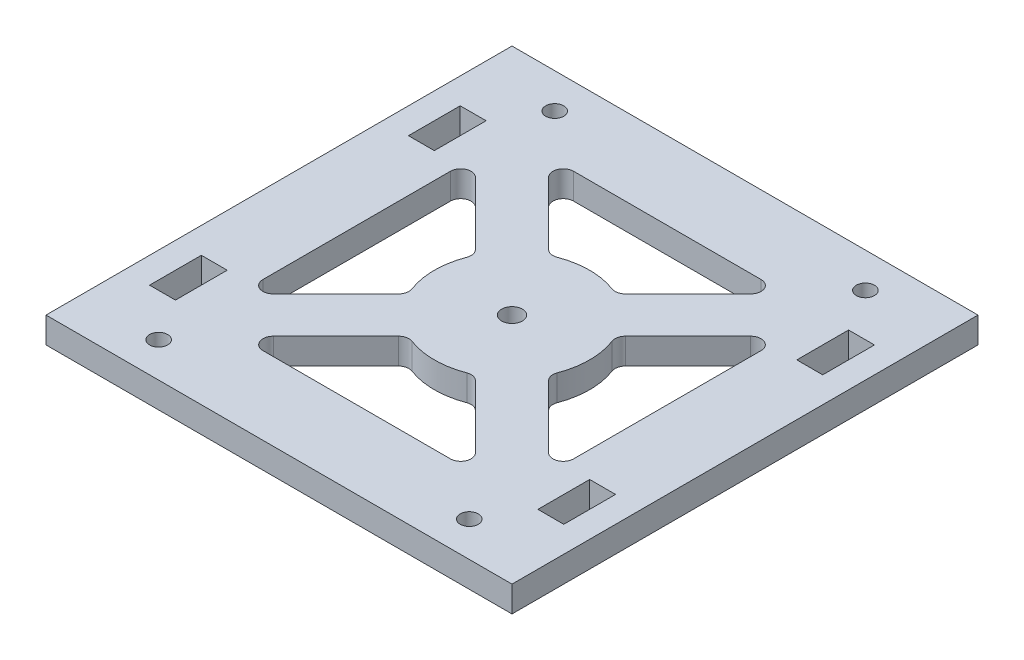
from build123d import *

# Parameters (mm, degrees)
SKETCH1_W               = 90
SKETCH1_H               = 90
SKETCH1_R               = 2
BOSS_EXTRUDE1_DEPTH     = 5
SKETCH2_R               = 1.75
SKETCH2_W               = 5
SKETCH2_H               = 10
CUT_EXTRUDE1_DEPTH      = 1
CUT_EXTRUDE1_DEPTH_BACK = 6


with BuildPart() as part:
    # Sketch1 → Boss-Extrude1 (new body)
    with BuildSketch(Plane(origin=(0, 0, 0), x_dir=(1, 0, 0), z_dir=(0, 1, 0))):
        Rectangle(SKETCH1_W, SKETCH1_H)
        Circle(SKETCH1_R, mode=Mode.SUBTRACT)
        with BuildLine():
            Line((-26.585786438, 19.514718626), (-14.489985056, 7.418917244))
            ThreePointArc((-14.489985056, 7.418917244), (-13.949056578, 6.425915745), (-14.033116428, 5.298267955))
            ThreePointArc((-14.033116428, 5.298267955), (-15, 0), (-14.033116428, -5.298267955))
            ThreePointArc((-14.033116428, -5.298267955), (-13.949056578, -6.425915745), (-14.489985056, -7.418917244))
            Line((-14.489985056, -7.418917244), (-26.585786438, -19.514718626))
            ThreePointArc((-26.585786438, -19.514718626), (-28.765366865, -19.948264128), (-30, -18.100505063))
            Line((-30, -18.100505063), (-30, 18.100505063))
            ThreePointArc((-30, 18.100505063), (-28.765366865, 19.948264128), (-26.585786438, 19.514718626))
        make_face(mode=Mode.SUBTRACT)
        with BuildLine():
            Line((-18.100505063, 30), (18.100505063, 30))
            ThreePointArc((18.100505063, 30), (19.948264128, 28.765366865), (19.514718626, 26.585786438))
            Line((19.514718626, 26.585786438), (7.418917244, 14.489985056))
            ThreePointArc((7.418917244, 14.489985056), (6.425915745, 13.949056578), (5.298267955, 14.033116428))
            ThreePointArc((5.298267955, 14.033116428), (0, 15), (-5.298267955, 14.033116428))
            ThreePointArc((-5.298267955, 14.033116428), (-6.425915745, 13.949056578), (-7.418917244, 14.489985056))
            Line((-7.418917244, 14.489985056), (-19.514718626, 26.585786438))
            ThreePointArc((-19.514718626, 26.585786438), (-19.948264128, 28.765366865), (-18.100505063, 30))
        make_face(mode=Mode.SUBTRACT)
        with BuildLine():
            Line((30, 18.100505063), (30, -18.100505063))
            ThreePointArc((30, -18.100505063), (28.765366865, -19.948264128), (26.585786438, -19.514718626))
            Line((26.585786438, -19.514718626), (14.489985056, -7.418917244))
            ThreePointArc((14.489985056, -7.418917244), (13.949056578, -6.425915745), (14.033116428, -5.298267955))
            ThreePointArc((14.033116428, -5.298267955), (15, 0), (14.033116428, 5.298267955))
            ThreePointArc((14.033116428, 5.298267955), (13.949056578, 6.425915745), (14.489985056, 7.418917244))
            Line((14.489985056, 7.418917244), (26.585786438, 19.514718626))
            ThreePointArc((26.585786438, 19.514718626), (28.765366865, 19.948264128), (30, 18.100505063))
        make_face(mode=Mode.SUBTRACT)
        with BuildLine():
            Line((19.514718626, -26.585786438), (7.418917244, -14.489985056))
            ThreePointArc((7.418917244, -14.489985056), (6.425915745, -13.949056578), (5.298267955, -14.033116428))
            ThreePointArc((5.298267955, -14.033116428), (0, -15), (-5.298267955, -14.033116428))
            ThreePointArc((-5.298267955, -14.033116428), (-6.425915745, -13.949056578), (-7.418917244, -14.489985056))
            Line((-7.418917244, -14.489985056), (-19.514718626, -26.585786438))
            ThreePointArc((-19.514718626, -26.585786438), (-19.948264128, -28.765366865), (-18.100505063, -30))
            Line((-18.100505063, -30), (18.100505063, -30))
            ThreePointArc((18.100505063, -30), (19.948264128, -28.765366865), (19.514718626, -26.585786438))
        make_face(mode=Mode.SUBTRACT)
    extrude(amount=BOSS_EXTRUDE1_DEPTH)

    # Sketch2 → Cut-Extrude1 (cut, two sides)
    with BuildSketch(Plane(origin=(0, 5, 0), x_dir=(1, 0, 0), z_dir=(0, 1, 0))) as cut_extrude1_sk:
        with Locations((-30, -38.25)):
            Circle(SKETCH2_R)
        with Locations((30, -38.25)):
            Circle(SKETCH2_R)
        with Locations((30, 38.25)):
            Circle(SKETCH2_R)
        with Locations((-30, 38.25)):
            Circle(SKETCH2_R)
        with Locations((37.5, 25)):
            Rectangle(SKETCH2_W, SKETCH2_H)
        with Locations((37.5, -25)):
            Rectangle(SKETCH2_W, SKETCH2_H)
        with Locations((-37.5, -25)):
            Rectangle(SKETCH2_W, SKETCH2_H)
        with Locations((-37.5, 25)):
            Rectangle(SKETCH2_W, SKETCH2_H)
    extrude(amount=CUT_EXTRUDE1_DEPTH, mode=Mode.SUBTRACT)
    extrude(cut_extrude1_sk.sketch, amount=-CUT_EXTRUDE1_DEPTH_BACK, mode=Mode.SUBTRACT)


solid = part.part
